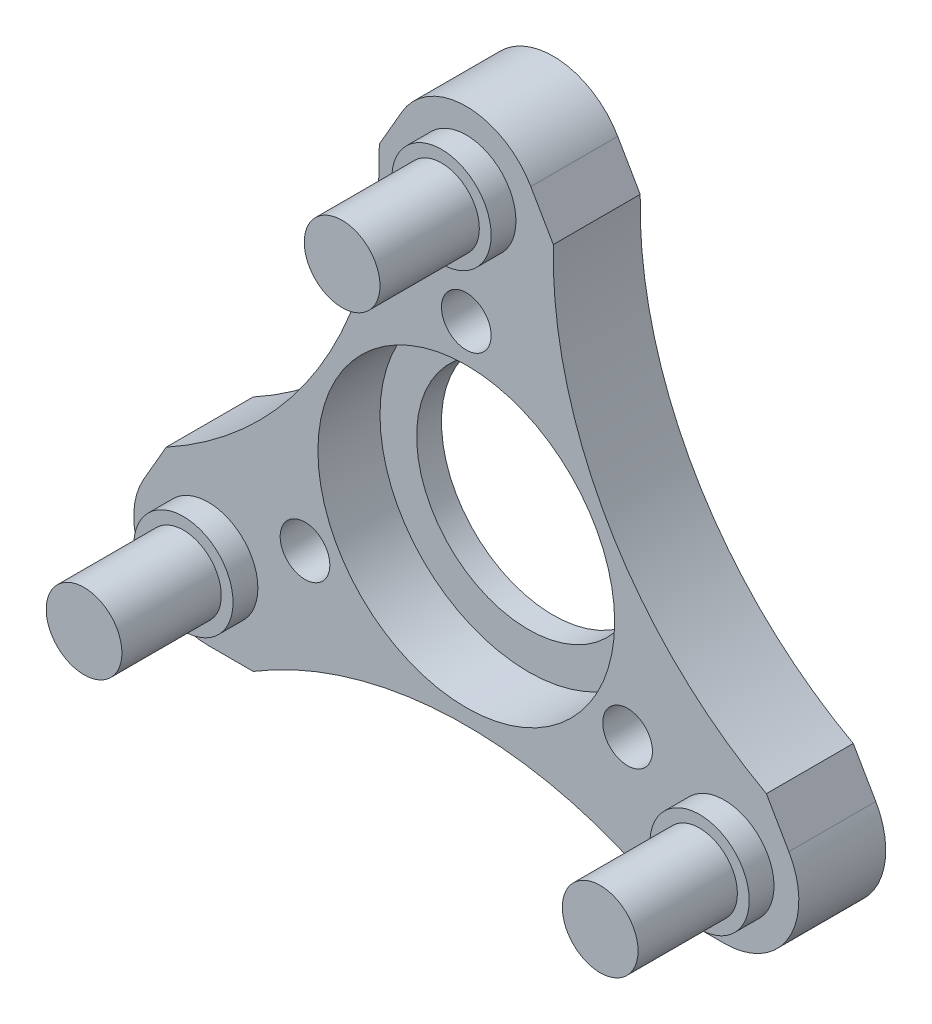
from build123d import *

# Parameters (mm, degrees)
EXTRUDE_1_DEPTH     = 2.5
FILLET_1_R          = 3
SKETCH_2_R          = 1.525
EXTRUDE_2_DEPTH     = 5
SKETCH_3_R          = 2
EXTRUDE_3_DEPTH     = 1
SKETCH_4_R          = 5.975
CUT_EXTRUDE_1_DEPTH = 10
EXTRUDE_4_DEPTH     = 1
SKETCH_6_R          = 4.5
CUT_EXTRUDE_2_DEPTH = 1
SKETCH_7_R          = 1
CUT_EXTRUDE_3_DEPTH = 10
SKETCH_9_R          = 16.5
CUT_EXTRUDE_4_DEPTH = 10


with BuildPart() as part:
    # 草图1 → 凸台-拉伸1 (new body)
    with BuildSketch(Plane.XY):
        Polygon((-15.588457268, -9), (15.588457268, -9), (0, 18), align=None)
        Polygon((10.392304845, -6), (0, 12), (-10.392304845, -6), align=None, mode=Mode.SUBTRACT)
        Polygon((-10.392304845, -6), (10.392304845, -6), (0, 12), align=None)
    extrude(amount=EXTRUDE_1_DEPTH)

    # 圆角1
    fillet_1_edges = [part.edges().sort_by_distance(p)[0] for p in [
        (-15.588457268, -9, 1.25),
        (0, 18, 1.25),
        (15.588457268, -9, 1.25),
    ]]
    fillet(fillet_1_edges, radius=FILLET_1_R)

    # 草图2 → 凸台-拉伸2 (add)
    with BuildSketch(Plane.XY.offset(2.5)):
        with Locations((0, 12)):
            Circle(SKETCH_2_R)
        with Locations((10.392304845, -6)):
            Circle(SKETCH_2_R)
        with Locations((-10.392304845, -6)):
            Circle(SKETCH_2_R)
    extrude(amount=EXTRUDE_2_DEPTH)

    # 草图3 → 凸台-拉伸3 (add)
    with BuildSketch(Plane.XY.offset(2.5)):
        with Locations((0, 12)):
            Circle(SKETCH_3_R)
        with Locations((10.392304845, -6)):
            Circle(SKETCH_3_R)
        with Locations((-10.392304845, -6)):
            Circle(SKETCH_3_R)
    extrude(amount=EXTRUDE_3_DEPTH)

    # 草图4 → 切除-拉伸1 (cut)
    with BuildSketch(Plane(origin=(0, 0, 0), x_dir=(-1, 0, 0), z_dir=(0, 0, -1))):
        Circle(SKETCH_4_R)
    extrude(amount=-CUT_EXTRUDE_1_DEPTH, mode=Mode.SUBTRACT)

    # 草图5 → 凸台-拉伸4 (add)
    with BuildSketch(Plane(origin=(0, 0, 0), x_dir=(-1, 0, 0), z_dir=(0, 0, -1))):
        with BuildLine():
            Line((-10.392304845, -9), (10.392304845, -9))
            ThreePointArc((10.392304845, -9), (12.990381057, -7.5), (12.990381057, -4.5))
            Line((12.990381057, -4.5), (2.598076211, 13.5))
            ThreePointArc((2.598076211, 13.5), (0, 15), (-2.598076211, 13.5))
            Line((-2.598076211, 13.5), (-12.990381057, -4.5))
            ThreePointArc((-12.990381057, -4.5), (-12.990381057, -7.5), (-10.392304845, -9))
        make_face()
    extrude(amount=EXTRUDE_4_DEPTH)

    # 草图6 → 切除-拉伸2 (cut)
    with BuildSketch(Plane.XY):
        Circle(SKETCH_6_R)
    extrude(amount=-CUT_EXTRUDE_2_DEPTH, mode=Mode.SUBTRACT)

    # 草图7 → 切除-拉伸3 (cut)
    with BuildSketch(Plane.XY.offset(2.5)):
        with Locations((0, 7.5)):
            Circle(SKETCH_7_R)
        with Locations((6.495190528, -3.75)):
            Circle(SKETCH_7_R)
        with Locations((-6.495190528, -3.75)):
            Circle(SKETCH_7_R)
    extrude(amount=-CUT_EXTRUDE_3_DEPTH, mode=Mode.SUBTRACT)

    # 草图9 → 切除-拉伸4 (cut)
    with BuildSketch(Plane.XY.offset(2.5)):
        with Locations((-20, 11.547005384)):
            Circle(SKETCH_9_R)
        with Locations((20, 11.547005384)):
            Circle(SKETCH_9_R)
        with Locations((0, -23.094010768)):
            Circle(SKETCH_9_R)
    extrude(amount=-CUT_EXTRUDE_4_DEPTH, mode=Mode.SUBTRACT)


solid = part.part
